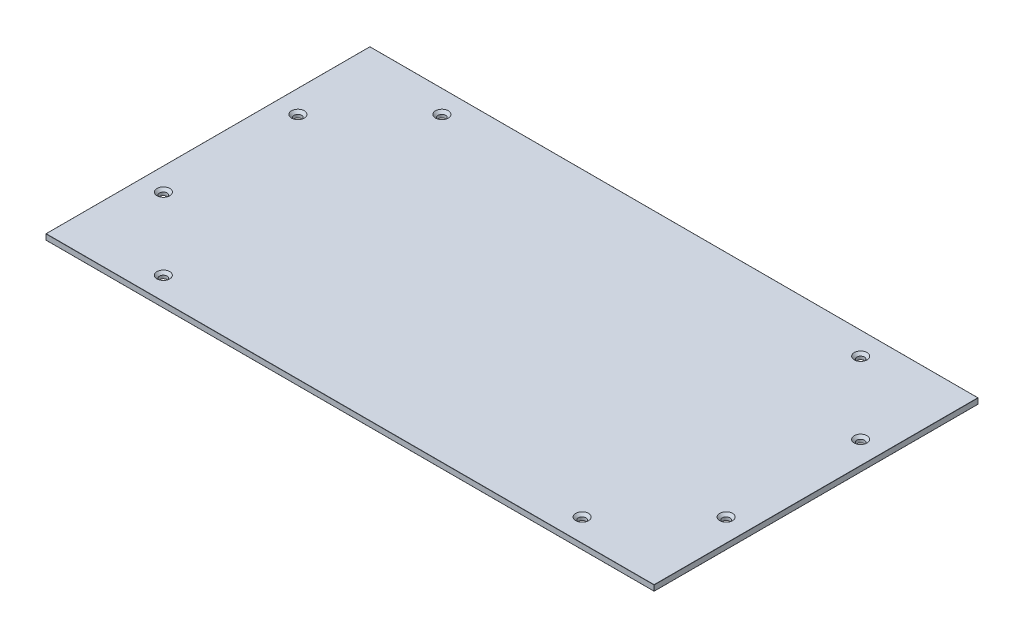
from build123d import *

# Parameters (mm, degrees)
SKETCH1_W           = 642
SKETCH1_H           = 342
BOSS_EXTRUDE1_DEPTH = 6
SKETCH2_R           = 4
CUT_EXTRUDE1_DEPTH  = 7
CHAMFER1_SIZE       = 2.75
FILLET1_R           = 0.2


with BuildPart() as part:
    # Sketch1 → Boss-Extrude1 (new body)
    with BuildSketch(Plane(origin=(0, 0, 0), x_dir=(1, 0, 0), z_dir=(0, 1, 0))):
        Rectangle(SKETCH1_W, SKETCH1_H)
    extrude(amount=BOSS_EXTRUDE1_DEPTH)

    # Sketch2 → Cut-Extrude1 (cut, through all)
    with BuildSketch(Plane(origin=(0, 6, 0), x_dir=(1, 0, 0), z_dir=(0, 1, 0))):
        with Locations((-221, -147)):
            Circle(SKETCH2_R)
        with Locations((221, -147)):
            Circle(SKETCH2_R)
        with Locations((-297, -71)):
            Circle(SKETCH2_R)
        with Locations((297, -71)):
            Circle(SKETCH2_R)
        with Locations((297, 71)):
            Circle(SKETCH2_R)
        with Locations((221, 147)):
            Circle(SKETCH2_R)
        with Locations((-221, 147)):
            Circle(SKETCH2_R)
        with Locations((-297, 71)):
            Circle(SKETCH2_R)
    extrude(amount=-CUT_EXTRUDE1_DEPTH, mode=Mode.SUBTRACT)

    # Chamfer1
    chamfer1_edges = [part.edges().sort_by_distance(p)[0] for p in [
        (-225, 6, 147),
        (217, 6, 147),
        (-301, 6, 71),
        (293, 6, 71),
        (293, 6, -71),
        (217, 6, -147),
        (-225, 6, -147),
        (-301, 6, -71),
    ]]
    chamfer(chamfer1_edges, length=CHAMFER1_SIZE)

    # Fillet1
    fillet1_edges = [part.edges().sort_by_distance(p)[0] for p in [
        (-321, 6, 0),
        (0, 6, 171),
        (321, 6, 0),
        (0, 0, 171),
        (-321, 0, 0),
        (0, 0, -171),
        (321, 0, 0),
        (0, 6, -171),
        (321, 3, 171),
        (-321, 3, 171),
        (-321, 3, -171),
        (321, 3, -171),
    ]]
    fillet(fillet1_edges, radius=FILLET1_R)


solid = part.part
